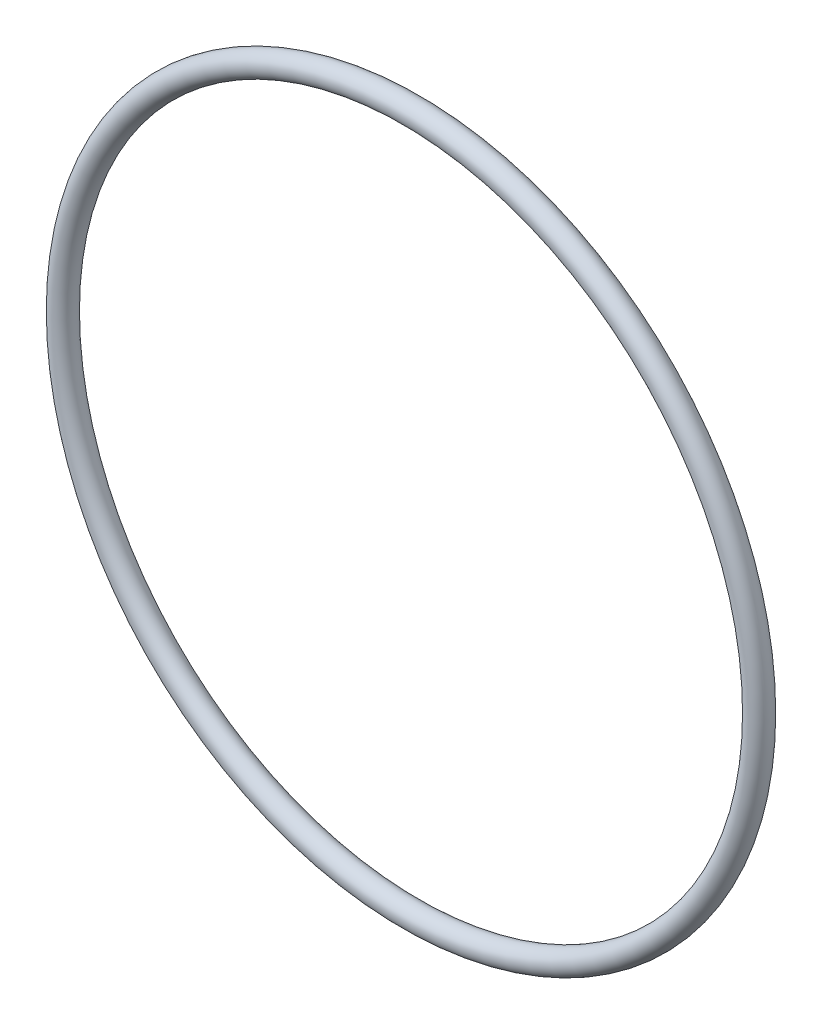
from build123d import *

# Parameters (mm, degrees)
SKETCH1_R = 1.7653


with BuildPart() as part:
    # Sketch1 → Revolve1 (revolve)
    with BuildSketch(Plane(origin=(0, 0, 0), x_dir=(0, -1, 0), z_dir=(1, 0, 0))):
        with Locations((52.3621, 0)):
            Circle(SKETCH1_R)
    revolve(axis=Axis((0, 0, 1.7653), (0, 0, -1)))


solid = part.part
